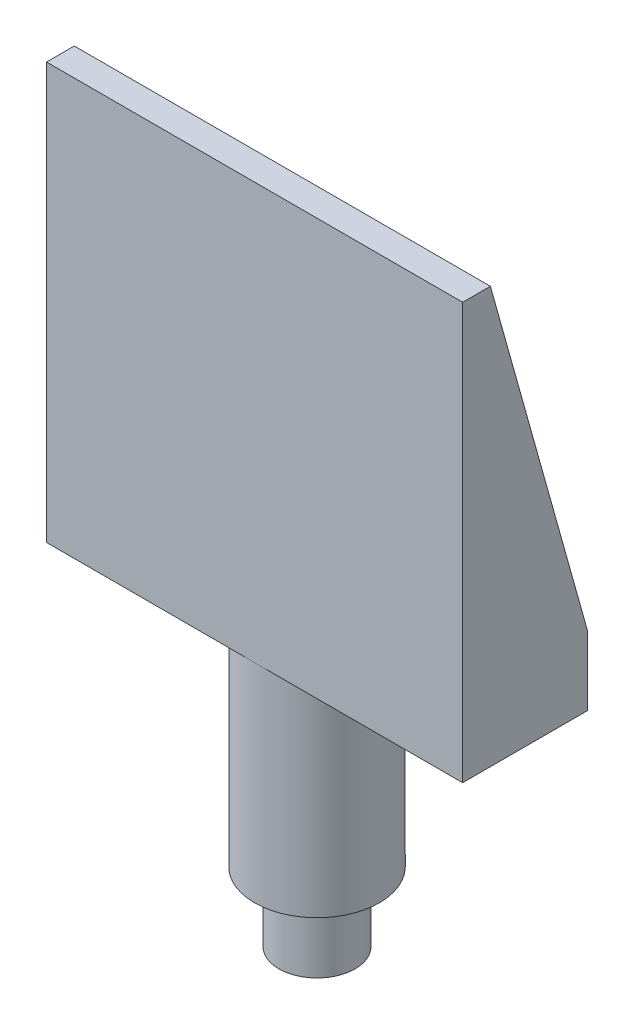
from build123d import *

# Parameters (mm, degrees)
SKETCH1_R           = 2.75
BOSS_EXTRUDE1_DEPTH = 5
SKETCH2_R           = 4.5
BOSS_EXTRUDE2_DEPTH = 15
SKETCH3_W           = 30
SKETCH3_H           = 9
BOSS_EXTRUDE3_DEPTH = 30
SKETCH4_W           = 26
SKETCH4_H           = 7
CUT_EXTRUDE1_DEPTH  = 25
CUT_EXTRUDE2_DEPTH  = 39


with BuildPart() as part:
    # Sketch1 → Boss-Extrude1 (new body)
    with BuildSketch(Plane(origin=(0, 0, 0), x_dir=(1, 0, 0), z_dir=(0, 1, 0))):
        Circle(SKETCH1_R)
    extrude(amount=BOSS_EXTRUDE1_DEPTH)

    # Sketch2 → Boss-Extrude2 (add)
    with BuildSketch(Plane(origin=(0, 5, 0), x_dir=(1, 0, 0), z_dir=(0, 1, 0))):
        Circle(SKETCH2_R)
    extrude(amount=BOSS_EXTRUDE2_DEPTH)

    # Sketch3 → Boss-Extrude3 (add)
    with BuildSketch(Plane(origin=(0, 20, 0), x_dir=(1, 0, 0), z_dir=(0, 1, 0))):
        Rectangle(SKETCH3_W, SKETCH3_H)
    extrude(amount=BOSS_EXTRUDE3_DEPTH)

    # Sketch4 → Cut-Extrude1 (cut)
    with BuildSketch(Plane(origin=(0, 50, 0), x_dir=(1, 0, 0), z_dir=(0, 1, 0))):
        with Locations((0, 1)):
            Rectangle(SKETCH4_W, SKETCH4_H)
    extrude(amount=-CUT_EXTRUDE1_DEPTH, mode=Mode.SUBTRACT)

    # Sketch5 → Cut-Extrude2 (cut)
    with BuildSketch(Plane(origin=(15, 0, 0), x_dir=(0, 0, -1), z_dir=(1, 0, 0))):
        Polygon((-2.5, 50), (4.5, 25), (4.5, 50), align=None)
    extrude(amount=-CUT_EXTRUDE2_DEPTH, mode=Mode.SUBTRACT)


solid = part.part
